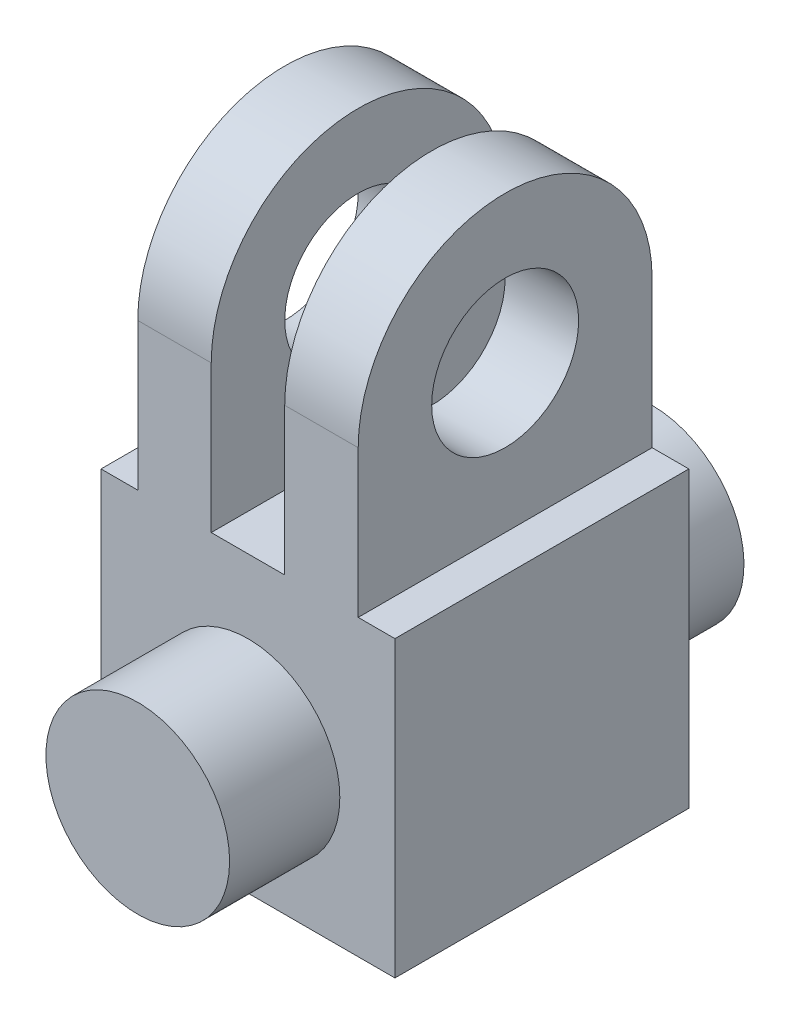
from build123d import *

# Parameters (mm, degrees)
CROQUIS2_R              = 20
SALIENTE_EXTRUIR1_DEPTH = 80
CORTAR_EXTRUIR1_REACH   = 82
CROQUIS3_W              = 10
CROQUIS3_H              = 80
CROQUIS3_W_2            = 20
CROQUIS4_R              = 25
SALIENTE_EXTRUIR2_DEPTH = 30
CROQUIS5_R              = 25
SALIENTE_EXTRUIR3_DEPTH = 30


with BuildPart() as part:
    # Croquis2 → Saliente-Extruir1 (new body)
    with BuildSketch(Plane(origin=(0, 0, 0), x_dir=(0, 0, -1), z_dir=(1, 0, 0))):
        with BuildLine():
            Line((0, 0), (80, 0))
            Line((80, 0), (80, 120))
            ThreePointArc((80, 120), (40, 160), (0, 120))
            Line((0, 120), (0, 0))
        make_face()
        with Locations((40, 120)):
            Circle(CROQUIS2_R, mode=Mode.SUBTRACT)
    extrude(amount=-SALIENTE_EXTRUIR1_DEPTH)

    # Croquis3 → Cortar-Extruir1 (cut, up to next)
    with BuildSketch(Plane.XY, mode=Mode.PRIVATE) as cortar_extruir1_sk1:
        with Locations((-5, 120)):
            Rectangle(CROQUIS3_W, CROQUIS3_H)
    cortar_extruir1_tool1 = extrude(cortar_extruir1_sk1.sketch, amount=-CORTAR_EXTRUIR1_REACH, mode=Mode.PRIVATE) & part.part
    add(cortar_extruir1_tool1.solids().sort_by_distance((-5, 120, 0))[0], mode=Mode.SUBTRACT)
    # Croquis3 → Cortar-Extruir1 (cut, up to next)
    with BuildSketch(Plane.XY, mode=Mode.PRIVATE) as cortar_extruir1_sk2:
        with Locations((-75, 120)):
            Rectangle(CROQUIS3_W, CROQUIS3_H)
    cortar_extruir1_tool2 = extrude(cortar_extruir1_sk2.sketch, amount=-CORTAR_EXTRUIR1_REACH, mode=Mode.PRIVATE) & part.part
    add(cortar_extruir1_tool2.solids().sort_by_distance((-75, 120, 0))[0], mode=Mode.SUBTRACT)
    # Croquis3 → Cortar-Extruir1 (cut, up to next)
    with BuildSketch(Plane.XY, mode=Mode.PRIVATE) as cortar_extruir1_sk3:
        with Locations((-40, 120)):
            Rectangle(CROQUIS3_W_2, CROQUIS3_H)
    cortar_extruir1_tool3 = extrude(cortar_extruir1_sk3.sketch, amount=-CORTAR_EXTRUIR1_REACH, mode=Mode.PRIVATE) & part.part
    add(cortar_extruir1_tool3.solids().sort_by_distance((-40, 120, 0))[0], mode=Mode.SUBTRACT)

    # Croquis4 → Saliente-Extruir2 (add)
    with BuildSketch(Plane.XY):
        with Locations((-40, 35)):
            Circle(CROQUIS4_R)
    extrude(amount=SALIENTE_EXTRUIR2_DEPTH)

    # Croquis5 → Saliente-Extruir3 (add)
    with BuildSketch(Plane(origin=(0, 0, -80), x_dir=(-1, 0, 0), z_dir=(0, 0, -1))):
        with Locations((40, 35)):
            Circle(CROQUIS5_R)
    extrude(amount=SALIENTE_EXTRUIR3_DEPTH)


solid = part.part
